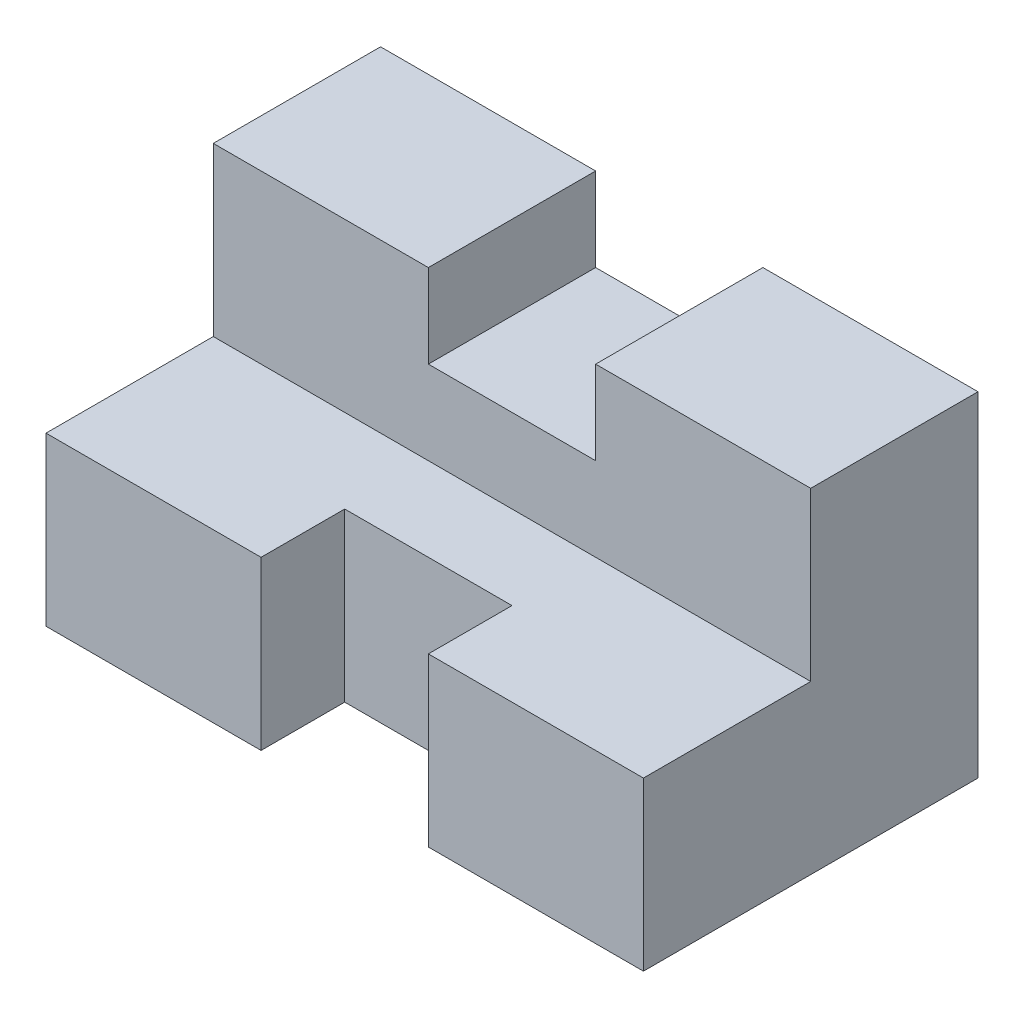
from build123d import *

# Parameters (mm, degrees)
EXTRUDE_1_DEPTH     = 25
CUT_EXTRUDE_1_REACH = 30
SKETCH_2_W          = 14
SKETCH_2_H          = 7
SKETCH_3_W          = 14
SKETCH_3_H          = 7
CUT_EXTRUDE_2_DEPTH = 29


with BuildPart() as part:
    # 스케치1 → 보스-돌출1 (new body, symmetric)
    with BuildSketch(Plane(origin=(0, 0, 0), x_dir=(0, 0, -1), z_dir=(1, 0, 0))):
        Polygon((0, 0), (28, 0), (28, 28), (14, 28), (14, 14), (0, 14), align=None)
    extrude(amount=EXTRUDE_1_DEPTH, both=True)

    # 스케치2 → 컷-돌출1 (cut, up to next)
    with BuildSketch(Plane(origin=(0, 0, 0), x_dir=(1, 0, 0), z_dir=(0, 1, 0)), mode=Mode.PRIVATE) as cut_extrude_1_sk1:
        with Locations((0, 3.5)):
            Rectangle(SKETCH_2_W, SKETCH_2_H)
    cut_extrude_1_tool1 = extrude(cut_extrude_1_sk1.sketch, amount=CUT_EXTRUDE_1_REACH, mode=Mode.PRIVATE) & part.part
    add(cut_extrude_1_tool1.solids().sort_by_distance((0, 0, -3.5))[0], mode=Mode.SUBTRACT)

    # 스케치3 → 컷-돌출2 (cut, through all)
    with BuildSketch(Plane.XY):
        with Locations((0, 24.5)):
            Rectangle(SKETCH_3_W, SKETCH_3_H)
    extrude(amount=-CUT_EXTRUDE_2_DEPTH, mode=Mode.SUBTRACT)


solid = part.part
